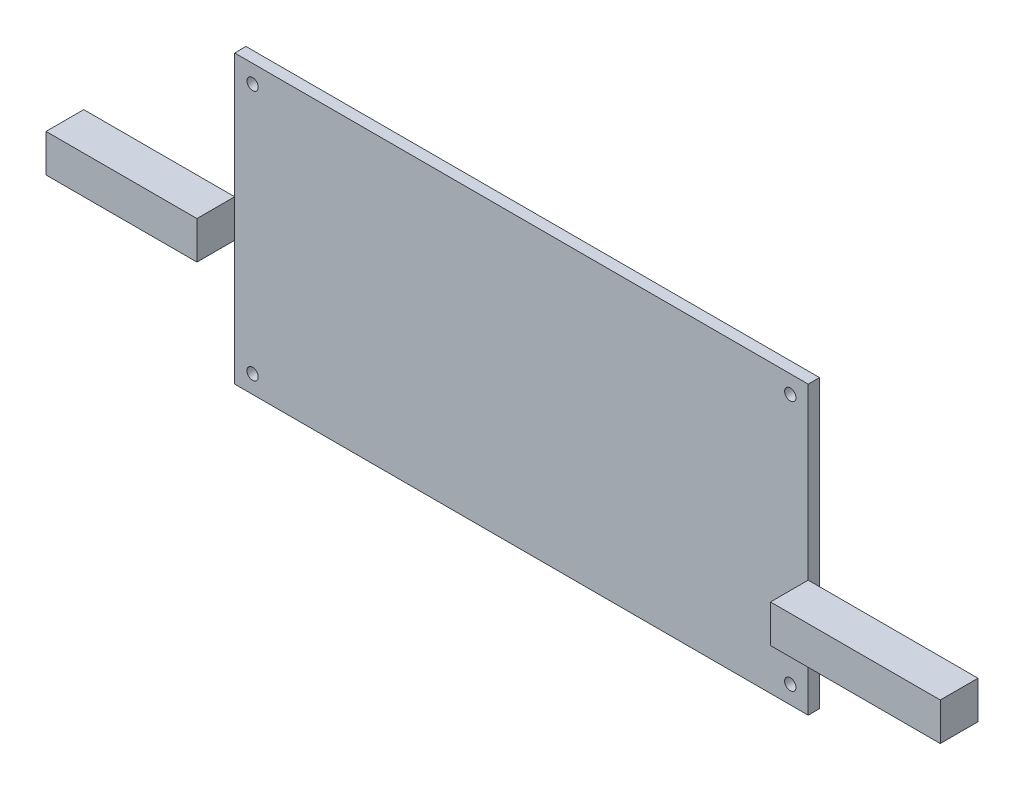
from build123d import *

# Parameters (mm, degrees)
SKETCH1_W               = 152
SKETCH1_H               = 76
BOSS_EXTRUDE1_DEPTH     = 1.5
SKETCH3_R               = 1.5
CUT_EXTRUDE1_DEPTH      = 2.5
CUT_EXTRUDE1_DEPTH_BACK = 2.5
SKETCH4_W               = 40
SKETCH4_H               = 10
BOSS_EXTRUDE2_DEPTH     = 10
SKETCH4_W_2             = 45
BOSS_EXTRUDE2_2_DEPTH   = 10


with BuildPart() as part:
    # Sketch1 → Boss-Extrude1 (new body, symmetric)
    with BuildSketch(Plane.XY):
        Rectangle(SKETCH1_W, SKETCH1_H)
    extrude(amount=BOSS_EXTRUDE1_DEPTH, both=True)

    # Sketch3 → Cut-Extrude1 (cut, two sides)
    with BuildSketch(Plane.XY) as cut_extrude1_sk:
        with Locations((-71.25, 33.25)):
            Circle(SKETCH3_R)
        with Locations((71.25, 33.25)):
            Circle(SKETCH3_R)
        with Locations((-71.25, -33.25)):
            Circle(SKETCH3_R)
        with Locations((71.25, -33.25)):
            Circle(SKETCH3_R)
    extrude(amount=CUT_EXTRUDE1_DEPTH, mode=Mode.SUBTRACT)
    extrude(cut_extrude1_sk.sketch, amount=-CUT_EXTRUDE1_DEPTH_BACK, mode=Mode.SUBTRACT)


with BuildPart() as body_2:
    # Sketch4 → Boss-Extrude2 (new body)
    with BuildSketch(Plane.XY.offset(1.5)):
        with Locations((-96, 0)):
            Rectangle(SKETCH4_W, SKETCH4_H)
    extrude(amount=BOSS_EXTRUDE2_DEPTH)


with BuildPart() as body_3:
    # Sketch4 → Boss-Extrude2 2 (new body)
    with BuildSketch(Plane.XY.offset(1.5)):
        with Locations((98.5, -12)):
            Rectangle(SKETCH4_W_2, SKETCH4_H)
    extrude(amount=BOSS_EXTRUDE2_2_DEPTH)


solid = Compound([part.part, body_2.part, body_3.part])
